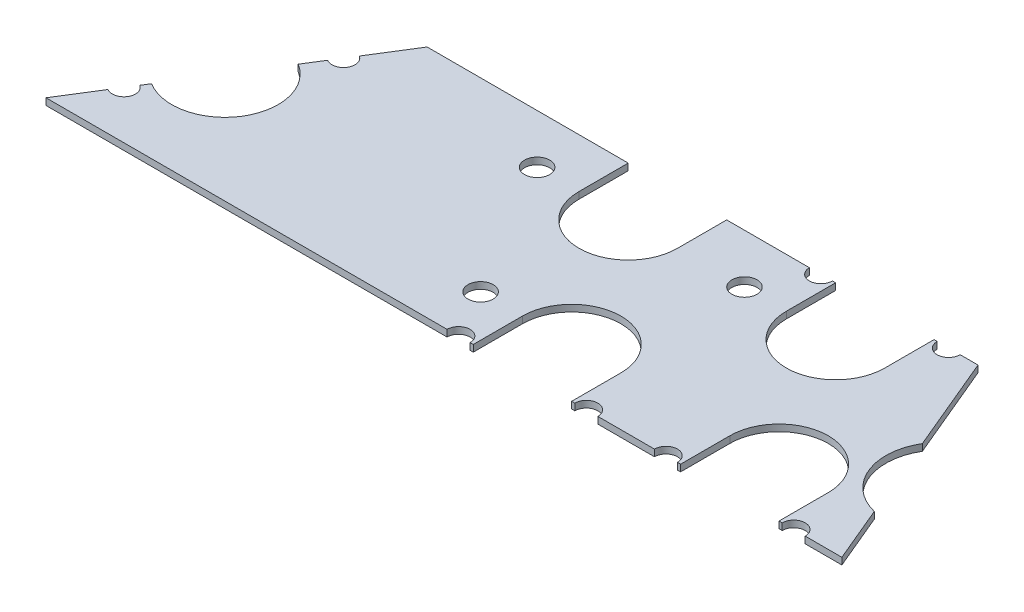
from build123d import *

# Parameters (mm, degrees)
SKETCH1_R           = 3
BOSS_EXTRUDE1_DEPTH = 1.6


with BuildPart() as part:
    # Sketch1 → Boss-Extrude1 (new body)
    with BuildSketch(Plane(origin=(0, 0, 0), x_dir=(1, 0, 0), z_dir=(0, 1, 0))):
        with BuildLine():
            ThreePointArc((95.75, 0), (98.5, 2.75), (101.25, 0))
            Line((101.25, 0), (102, 0))
            Line((102, 0), (102, 11.75))
            ThreePointArc((102, 11.75), (113.75, 23.5), (125.5, 11.75))
            Line((125.5, 11.75), (125.5, 0))
            Line((125.5, 0), (126.25, 0))
            ThreePointArc((126.25, 0), (129, 2.75), (131.75, 0))
            Line((131.75, 0), (145.25, 0))
            ThreePointArc((145.25, 0), (148, 2.75), (150.75, 0))
            Line((150.75, 0), (151.5, 0))
            Line((151.5, 0), (151.5, 11.75))
            ThreePointArc((151.5, 11.75), (163.25, 23.5), (175, 11.75))
            Line((175, 11.75), (175, 0))
            Line((175, 0), (175.75, 0))
            ThreePointArc((175.75, 0), (178.5, 2.75), (181.25, 0))
            Line((181.25, 0), (190, 0))
            Line((190, 0), (184.397294991, 13.35112683))
            ThreePointArc((184.397294991, 13.35112683), (175.255085608, 21.137460938), (176.103062866, 33.116105511))
            Line((176.103062866, 33.116105511), (166.5, 56))
            Line((166.5, 56), (162.25, 56))
            ThreePointArc((162.25, 56), (159.5, 53.25), (156.75, 56))
            Line((156.75, 56), (156, 56))
            Line((156, 56), (156, 44.25))
            ThreePointArc((156, 44.25), (144.25, 32.5), (132.5, 44.25))
            Line((132.5, 44.25), (132.5, 56))
            Line((132.5, 56), (131.75, 56))
            ThreePointArc((131.75, 56), (129, 53.25), (126.25, 56))
            Line((126.25, 56), (106.5, 56))
            Line((106.5, 56), (106.5, 44.25))
            ThreePointArc((106.5, 44.25), (94.75, 32.5), (83, 44.25))
            Line((83, 44.25), (83, 56))
            Line((83, 56), (35, 56))
            Line((35, 56), (28.772512455, 46.036019928))
            ThreePointArc((28.772512455, 46.036019928), (29.720282193, 45.037138056), (30.06501537, 43.704024592))
            ThreePointArc((30.06501537, 43.704024592), (28.648128834, 41.298757768), (25.857518285, 41.372029256))
            Line((25.857518285, 41.372029256), (23.160953678, 37.057525885))
            ThreePointArc((23.160953678, 37.057525885), (27.537926652, 32.444507786), (29.12996714, 26.287947424))
            ThreePointArc((29.12996714, 26.287947424), (22.586527501, 15.179987912), (9.698980602, 15.518368963))
            Line((9.698980602, 15.518368963), (8.612482775, 13.77997244))
            ThreePointArc((8.612482775, 13.77997244), (9.560252513, 12.781090568), (9.90498569, 11.447977104))
            ThreePointArc((9.90498569, 11.447977104), (8.488099154, 9.042710281), (5.697488605, 9.115981768))
            Line((5.697488605, 9.115981768), (0, 0))
            Line((0, 0), (95.75, 0))
        make_face()
        with Locations(Location((92, 11.75, 0), (0, 0, 270))):  # turned: the seam where the file's is
            Circle(SKETCH1_R, mode=Mode.SUBTRACT)
        with Locations(Location((73, 44.25, 0), (0, 0, 270))):  # turned: the seam where the file's is
            Circle(SKETCH1_R, mode=Mode.SUBTRACT)
        with Locations(Location((122.5, 44.25, 0), (0, 0, 270))):  # turned: the seam where the file's is
            Circle(SKETCH1_R, mode=Mode.SUBTRACT)
    extrude(amount=BOSS_EXTRUDE1_DEPTH)


solid = part.part
